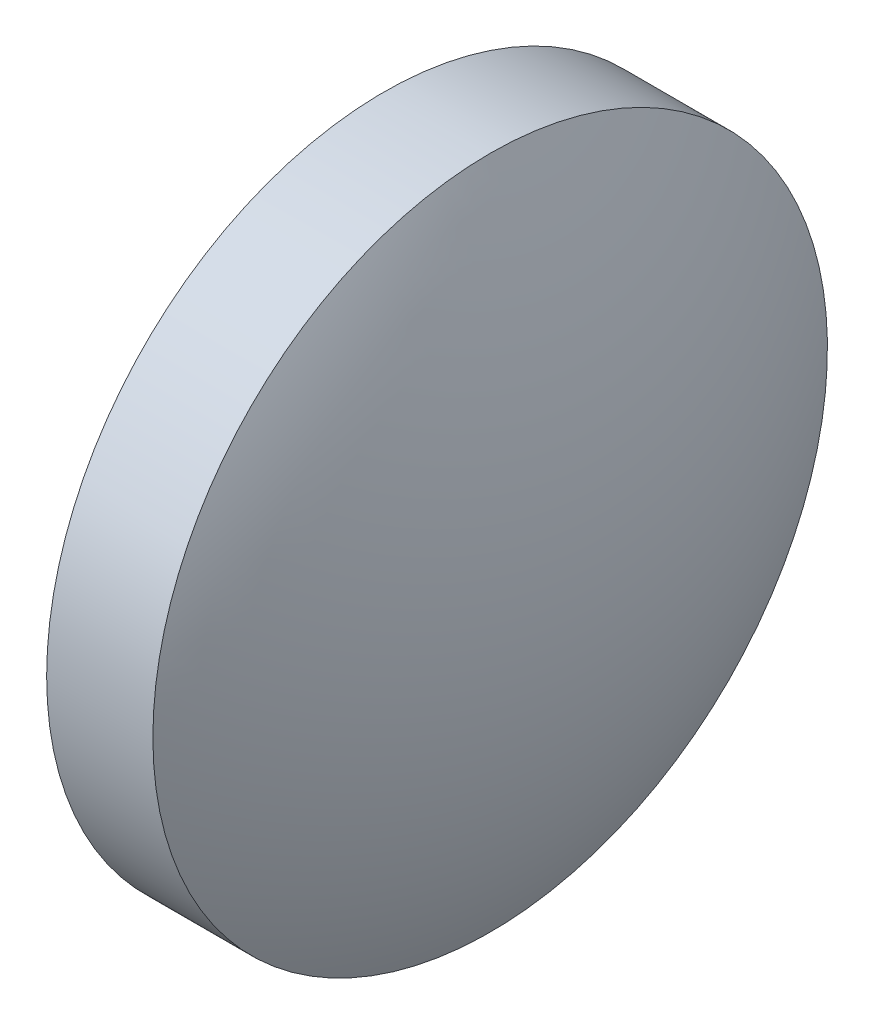
from build123d import *


with BuildPart() as part:
    # 草图1 → 旋转1 (revolve)
    with BuildSketch(Plane.XY):
        with BuildLine():
            Line((367.209293599, 34.69530443), (367.209293599, 41.04530443))
            Line((367.209293599, 41.04530443), (369.209293599, 41.04530443))
            ThreePointArc((369.209293599, 41.04530443), (370.373580289, 37.964711869), (370.769293599, 34.69530443))
            Line((370.769293599, 34.69530443), (367.209293599, 34.69530443))
        make_face()
    revolve(axis=Axis((364.881265109, 34.69530443, 0), (1, 0, 0)))


solid = part.part
